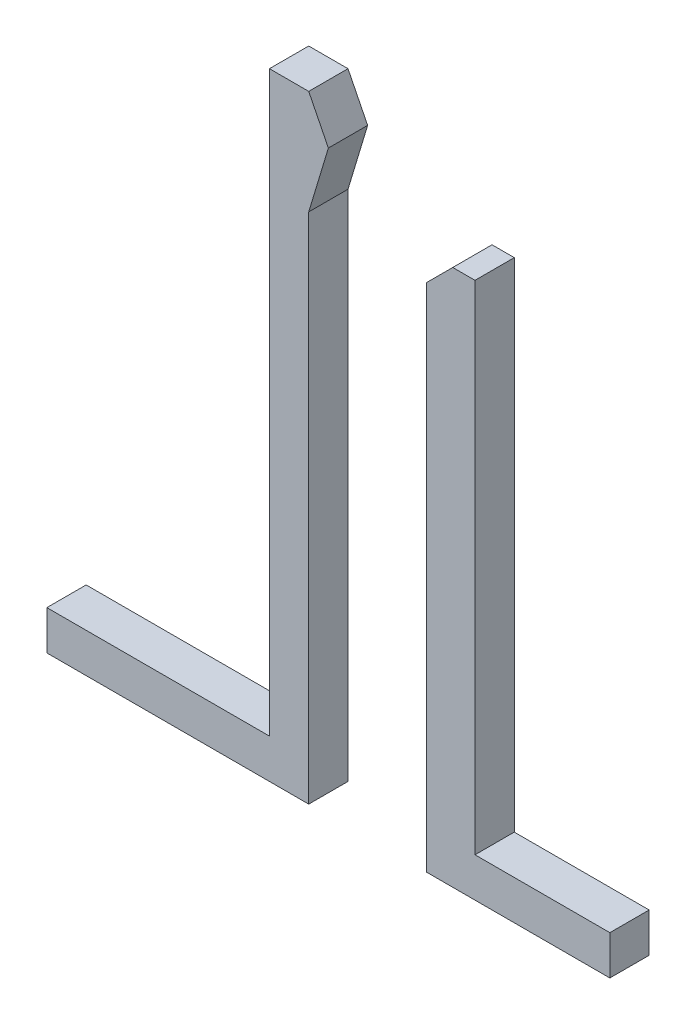
from build123d import *

# Parameters (mm, degrees)
RESSALTO_EXTRUS_O1_DEPTH   = 0.3
RESSALTO_EXTRUS_O1_2_DEPTH = 0.3


with BuildPart() as part:
    # Esboço1 → Ressalto-extrusão1 (new body)
    with BuildSketch(Plane.XY):
        Polygon((-2.35, -0.1), (-0.35, -0.1), (-0.35, 3.817407153), (-0.2, 4.314816679), (-0.35, 4.614816679), (-0.65, 4.614816679), (-0.65, 0.2), (-2.35, 0.2), align=None)
    extrude(amount=RESSALTO_EXTRUS_O1_DEPTH)


with BuildPart() as body_2:
    # Esboço1 → Ressalto-extrus_o1 2 (new body)
    with BuildSketch(Plane.XY):
        Polygon((1.95, -0.1), (0.55, -0.1), (0.55, 3.8), (0.75, 4), (0.92, 4), (0.92, 0.2), (1.95, 0.2), align=None)
    extrude(amount=RESSALTO_EXTRUS_O1_2_DEPTH)


solid = Compound([part.part, body_2.part])
